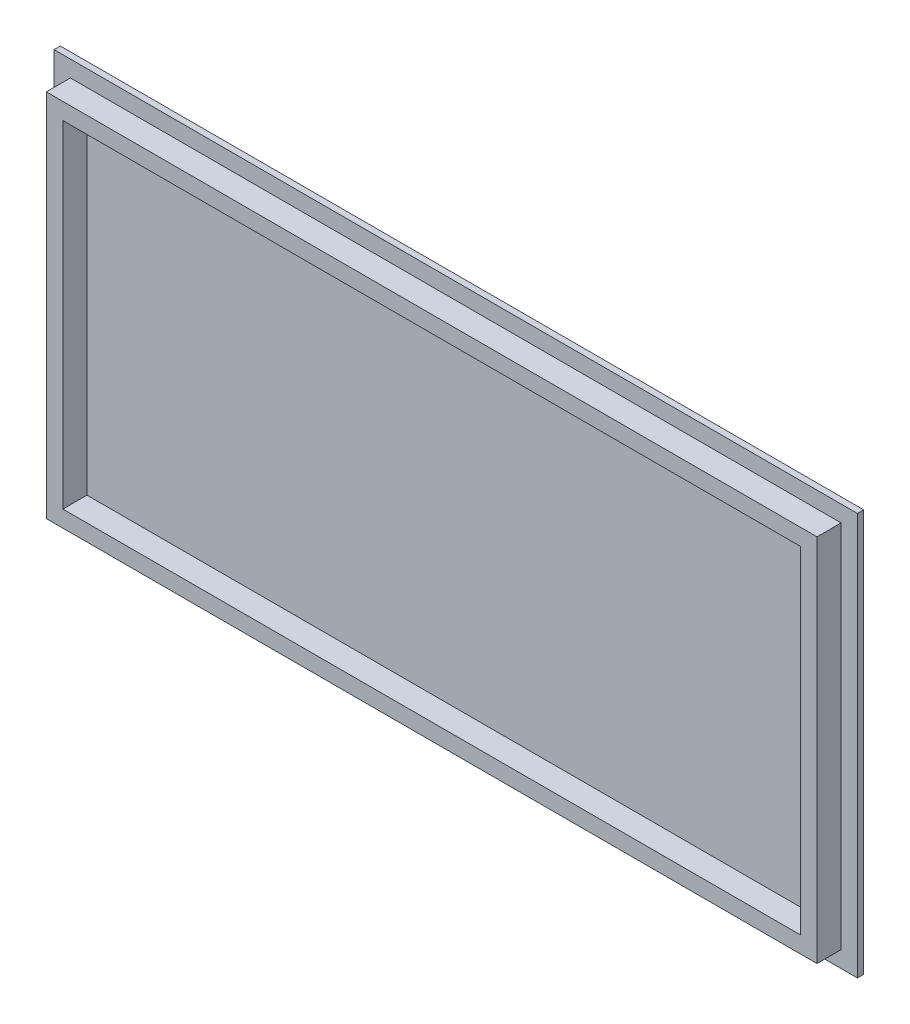
from build123d import *

# Parameters (mm, degrees)
SKETCH_5_W          = 383.47
SKETCH_5_H          = 192.04
EXTRUDE_2_DEPTH     = 3
EXTRUDE_START       = 3
SKETCH_6_W          = 367.88
SKETCH_6_H          = 176.41
EXTRUDE_3_DEPTH     = 11.5
CUT_EXTRUDE_START   = 14.5
SKETCH_7_W          = 352.07
SKETCH_7_H          = 160.62
CUT_EXTRUDE_1_DEPTH = 11.5


with BuildPart() as part:
    # 草图5 → 凸台-拉伸2 (new body)
    with BuildSketch(Plane.XY):
        with Locations((183.815306963, 88.27515573)):
            Rectangle(SKETCH_5_W, SKETCH_5_H)
    extrude(amount=EXTRUDE_2_DEPTH)

    # 草图6 → 凸台-拉伸3 (add)
    with BuildSketch(Plane.XY.offset(EXTRUDE_START)):
        with Locations((183.832314811, 88.286576554)):
            Rectangle(SKETCH_6_W, SKETCH_6_H)
    extrude(amount=EXTRUDE_3_DEPTH)

    # 草图7 → 切除-拉伸1 (cut)
    with BuildSketch(Plane.XY.offset(CUT_EXTRUDE_START)):
        with Locations((183.827427543, 88.282627)):
            Rectangle(SKETCH_7_W, SKETCH_7_H)
    extrude(amount=-CUT_EXTRUDE_1_DEPTH, mode=Mode.SUBTRACT)


solid = part.part
